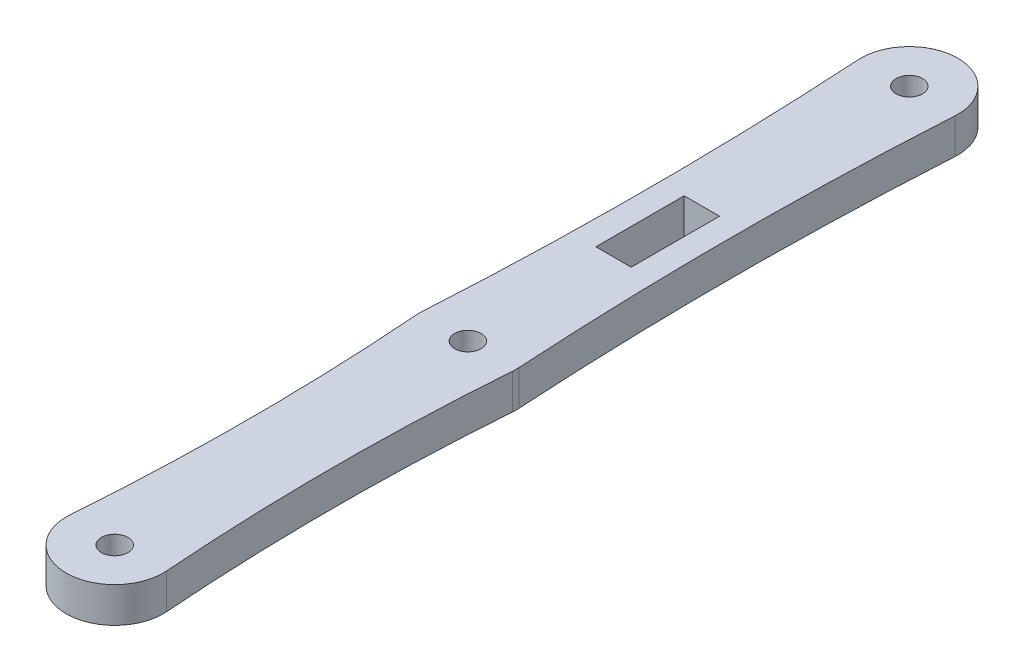
from build123d import *

# Parameters (mm, degrees)
SKETCH1_R           = 1.5
SKETCH1_W           = 4
SKETCH1_H           = 10
BOSS_EXTRUDE1_DEPTH = 4


with BuildPart() as part:
    # Sketch1 → Boss-Extrude1 (new body)
    with BuildSketch(Plane(origin=(0, 0, 0), x_dir=(1, 0, 0), z_dir=(0, 1, 0))):
        with BuildLine():
            ThreePointArc((-5.484552972, 0.411920736), (0, -5.5), (5.484552972, 0.411920736))
            ThreePointArc((5.484552972, 0.411920736), (4.75, 20), (5.484552972, 39.588079264))
            ThreePointArc((5.484552972, 39.588079264), (5.499845666, 39.95879751), (5.490108902, 40.329703267))
            ThreePointArc((5.490108902, 40.329703267), (4.75, 65), (5.490108902, 89.670296733))
            ThreePointArc((5.490108902, 89.670296733), (0, 95.5), (-5.490108902, 89.670296733))
            ThreePointArc((-5.490108902, 89.670296733), (-4.75, 65), (-5.490108902, 40.329703267))
            ThreePointArc((-5.490108902, 40.329703267), (-5.499845666, 39.95879751), (-5.484552972, 39.588079264))
            ThreePointArc((-5.484552972, 39.588079264), (-4.75, 20), (-5.484552972, 0.411920736))
        make_face()
        Circle(SKETCH1_R, mode=Mode.SUBTRACT)
        with Locations((0, 90)):
            Circle(SKETCH1_R, mode=Mode.SUBTRACT)
        with Locations((0, 40)):
            Circle(SKETCH1_R, mode=Mode.SUBTRACT)
        with Locations((0, 61.5)):
            Rectangle(SKETCH1_W, SKETCH1_H, mode=Mode.SUBTRACT)
    extrude(amount=BOSS_EXTRUDE1_DEPTH)


solid = part.part
